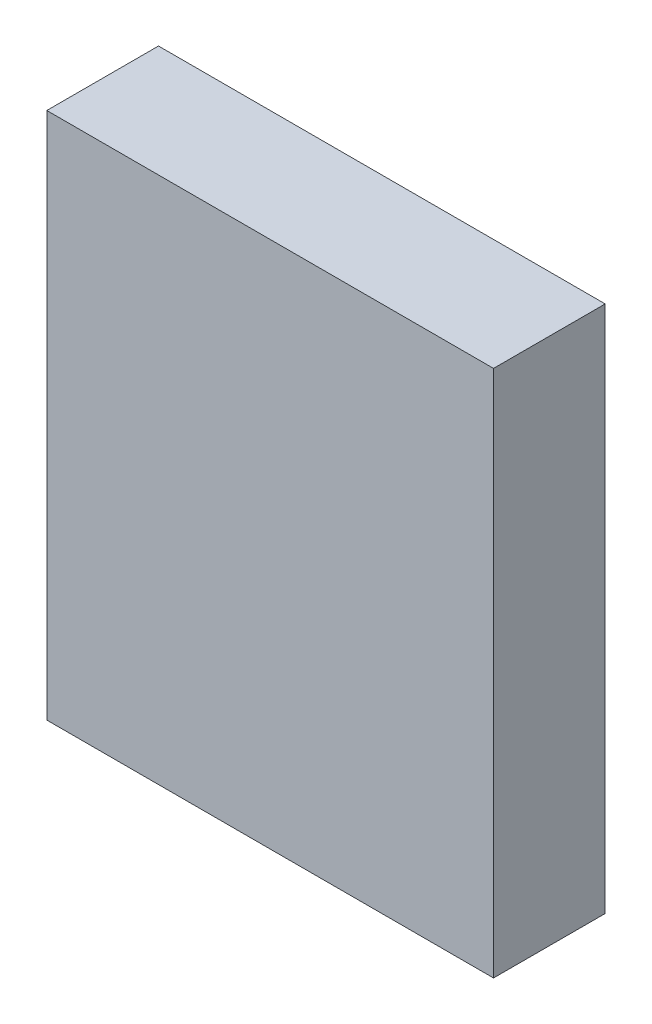
from build123d import *

# Parameters (mm, degrees)
SCHIZZO1_W                   = 44
SCHIZZO1_H                   = 52
ESTRUSIONE_ESTRUSIONE1_DEPTH = 11


with BuildPart() as part:
    # Schizzo1 → Estrusione-Estrusione1 (new body)
    with BuildSketch(Plane.XY):
        with Locations((22, 26)):
            Rectangle(SCHIZZO1_W, SCHIZZO1_H)
    extrude(amount=ESTRUSIONE_ESTRUSIONE1_DEPTH)


solid = part.part
